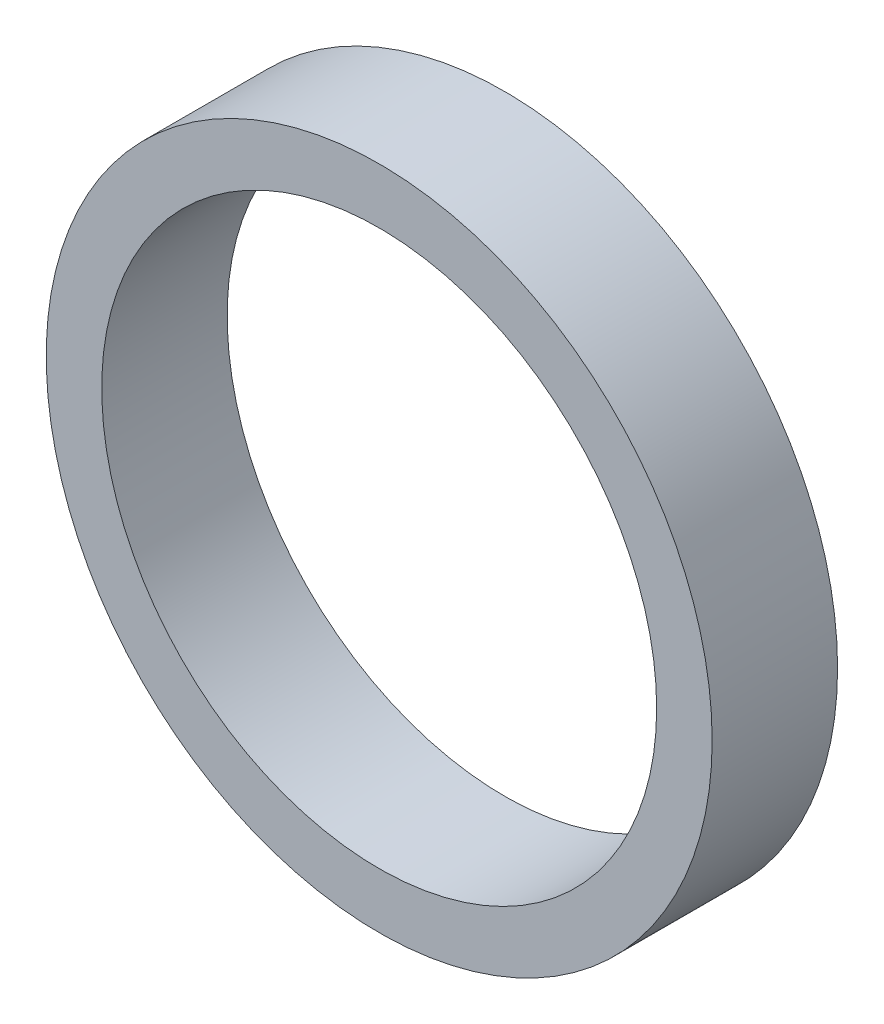
from build123d import *

# Parameters (mm, degrees)
SZKIC1_R                    = 15
SZKIC1_R_2                  = 12.5
DODANIE_WYCI_GNI_CIE1_DEPTH = 5.65


with BuildPart() as part:
    # Szkic1 → Dodanie-wyciągnięcie1 (new body)
    with BuildSketch(Plane.XY):
        Circle(SZKIC1_R)
        Circle(SZKIC1_R_2, mode=Mode.SUBTRACT)
    extrude(amount=DODANIE_WYCI_GNI_CIE1_DEPTH)


solid = part.part
